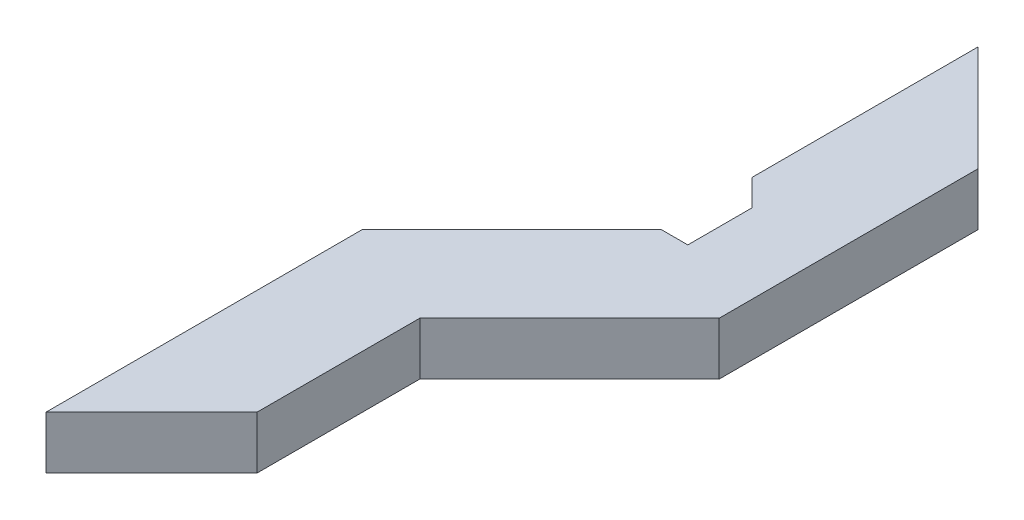
from build123d import *

# Parameters (mm, degrees)
BOSS_EXTRUDE1_DEPTH = 5


with BuildPart() as part:
    # Sketch1 → Boss-Extrude1 (new body)
    with BuildSketch(Plane(origin=(0, 0, 0), x_dir=(1, 0, 0), z_dir=(0, 1, 0))):
        Polygon((3.897080063, -25.431241822), (3.897080063, 4.568758178), (18.039215686, 18.710893802), (20.582899937, 18.710893802), (20.582899937, 24.772596922), (18.084256617, 27.316281172), (18.084256617, 48.71085999), (28.084256617, 38.71085999), (28.084256617, 14.187176554), (13.897080063, 0), (13.897080063, -15.431241822), align=None)
    extrude(amount=BOSS_EXTRUDE1_DEPTH)


solid = part.part
